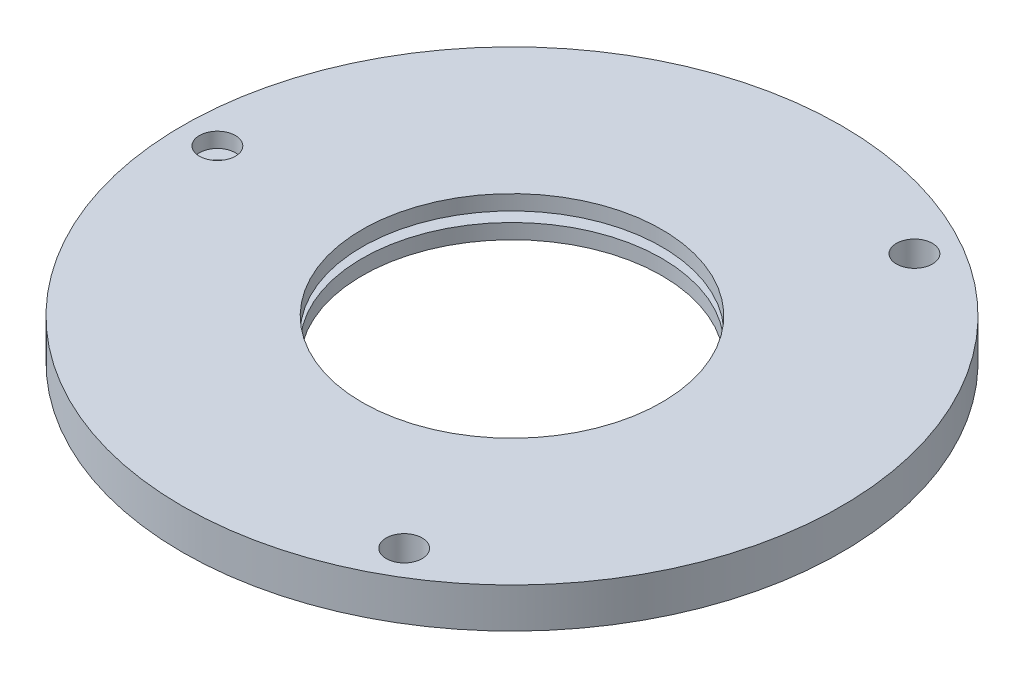
from build123d import *

# Parameters (mm, degrees)
SKETCH1_R                                       = 33
SKETCH1_R_2                                     = 1.5
BOSS_EXTRUDE1_DEPTH                             = 4
CSK_FOR_M3_FLAT_HEAD_MACHINE_SCREW1_D           = 3.6
CSK_FOR_M3_FLAT_HEAD_MACHINE_SCREW1_CSINK_D     = 6.3
CSK_FOR_M3_FLAT_HEAD_MACHINE_SCREW1_CSINK_ANGLE = 90
CORTAR_EXTRUIR1_REACH                           = 48.84
CROQUIS1_R                                      = 15
CROQUIS2_W                                      = 40
CROQUIS2_H                                      = 1
CORTAR_EXTRUIR2_DEPTH                           = 50


with BuildPart() as part:
    # Sketch1 → Boss-Extrude1 (new body)
    with BuildSketch(Plane(origin=(0, 0, 0), x_dir=(1, 0, 0), z_dir=(0, 1, 0))):
        Circle(SKETCH1_R)
        with Locations((-29.5, 0)):
            Circle(SKETCH1_R_2, mode=Mode.SUBTRACT)
        with Locations((14.75, 25.547749412)):
            Circle(SKETCH1_R_2, mode=Mode.SUBTRACT)
        with Locations((14.75, -25.547749412)):
            Circle(SKETCH1_R_2, mode=Mode.SUBTRACT)
    extrude(amount=BOSS_EXTRUDE1_DEPTH)

    # CSK for M3 Flat Head Machine Screw1 (through all)
    with Locations(Plane(origin=(0, 0, 0), x_dir=(-1, 0, 0), z_dir=(0, -1, 0))):
        with Locations((-14.75, -25.547749412), (29.5, 0), (-14.75, 25.547749412)):
            CounterSinkHole(CSK_FOR_M3_FLAT_HEAD_MACHINE_SCREW1_D / 2, CSK_FOR_M3_FLAT_HEAD_MACHINE_SCREW1_CSINK_D / 2, counter_sink_angle=CSK_FOR_M3_FLAT_HEAD_MACHINE_SCREW1_CSINK_ANGLE)

    # Croquis1 → Cortar-Extruir1 (cut, up to next)
    with BuildSketch(Plane.XZ, mode=Mode.PRIVATE) as cortar_extruir1_sk1:
        Circle(CROQUIS1_R)
    cortar_extruir1_tool1 = extrude(cortar_extruir1_sk1.sketch, amount=-CORTAR_EXTRUIR1_REACH, mode=Mode.PRIVATE) & part.part
    add(cortar_extruir1_tool1.solids().sort_by_distance((0, 0, 0))[0], mode=Mode.SUBTRACT)

    # Croquis2 → Cortar-Extruir2 (cut)
    with BuildSketch(Plane.ZY.offset(33)):
        with Locations((0, 2)):
            Rectangle(CROQUIS2_W, CROQUIS2_H)
    extrude(amount=-CORTAR_EXTRUIR2_DEPTH, mode=Mode.SUBTRACT)


solid = part.part
